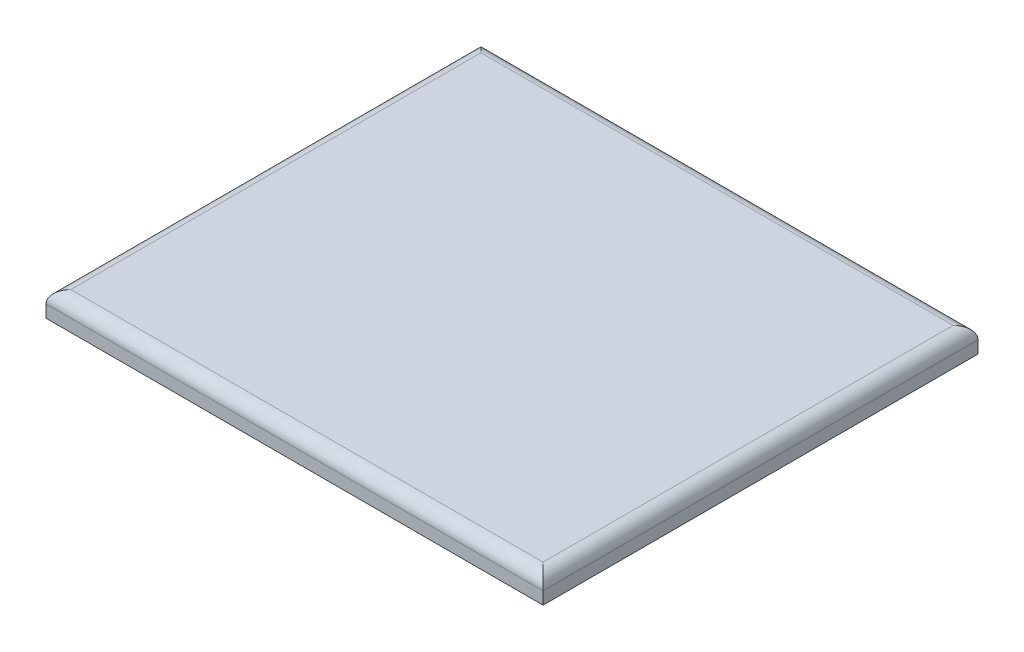
from build123d import *

# Parameters (mm, degrees)
SKETCH1_W           = 400
SKETCH1_H           = 350
BOSS_EXTRUDE1_DEPTH = 20
FILLET1_R           = 10


with BuildPart() as part:
    # Sketch1 → Boss-Extrude1 (new body)
    with BuildSketch(Plane(origin=(0, 0, 0), x_dir=(1, 0, 0), z_dir=(0, 1, 0))):
        Rectangle(SKETCH1_W, SKETCH1_H)
    extrude(amount=BOSS_EXTRUDE1_DEPTH)

    # Fillet1
    fillet1_edges = [part.edges().sort_by_distance(p)[0] for p in [
        (-200, 20, 0),
        (0, 20, 175),
        (200, 20, 0),
        (0, 20, -175),
    ]]
    fillet(fillet1_edges, radius=FILLET1_R)


solid = part.part
